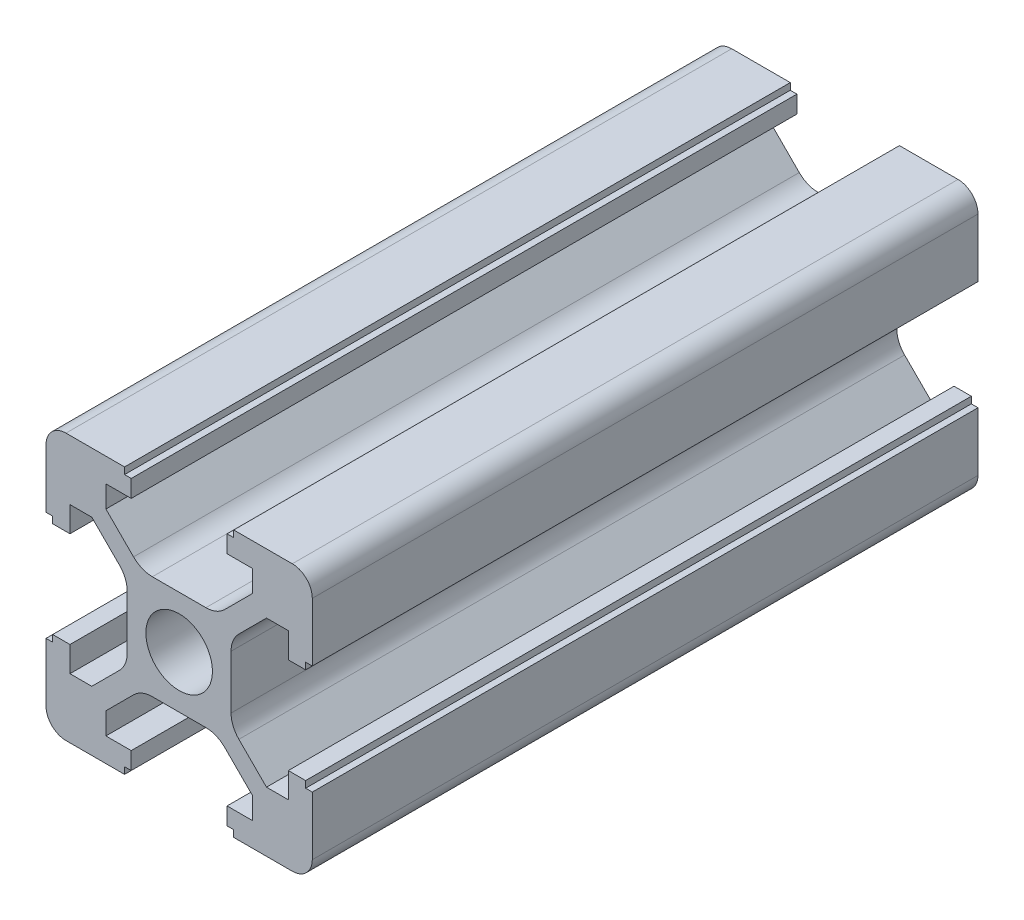
from build123d import *

# Parameters (mm, degrees)
SKETCH1_R           = 2.5
BOSS_EXTRUDE2_DEPTH = 50


with BuildPart() as part:
    # Sketch1 → Boss-Extrude2 (new body)
    with BuildSketch(Plane.XY):
        with BuildLine():
            Line((10, -4.1), (10, -8.5))
            ThreePointArc((10, -8.5), (9.560660172, -9.560660172), (8.5, -10))
            Line((8.5, -10), (4.1, -10))
            Line((4.1, -10), (4.1, -9.5))
            Line((4.1, -9.5), (3.6, -9.5))
            Line((3.6, -9.5), (3.6, -8.2))
            Line((3.6, -8.2), (5.5, -8.2))
            Line((5.5, -8.2), (5.5, -6.560660172))
            Line((5.5, -6.560660172), (3.425126266, -4.485786438))
            ThreePointArc((3.425126266, -4.485786438), (2.776279568, -4.052240935), (2.010912703, -3.9))
            Line((2.010912703, -3.9), (-2.010912703, -3.9))
            ThreePointArc((-2.010912703, -3.9), (-2.776279568, -4.052240935), (-3.425126266, -4.485786438))
            Line((-3.425126266, -4.485786438), (-5.5, -6.560660172))
            Line((-5.5, -6.560660172), (-5.5, -8.2))
            Line((-5.5, -8.2), (-3.6, -8.2))
            Line((-3.6, -8.2), (-3.6, -9.5))
            Line((-3.6, -9.5), (-4.1, -9.5))
            Line((-4.1, -9.5), (-4.1, -10))
            Line((-4.1, -10), (-8.5, -10))
            ThreePointArc((-8.5, -10), (-9.560660172, -9.560660172), (-10, -8.5))
            Line((-10, -8.5), (-10, -4.1))
            Line((-10, -4.1), (-9.5, -4.1))
            Line((-9.5, -4.1), (-9.5, -3.6))
            Line((-9.5, -3.6), (-8.2, -3.6))
            Line((-8.2, -3.6), (-8.2, -5.5))
            Line((-8.2, -5.5), (-6.560660172, -5.5))
            Line((-6.560660172, -5.5), (-4.485786438, -3.425126266))
            ThreePointArc((-4.485786438, -3.425126266), (-4.052240935, -2.776279568), (-3.9, -2.010912703))
            Line((-3.9, -2.010912703), (-3.9, 2.010912703))
            ThreePointArc((-3.9, 2.010912703), (-4.052240935, 2.776279568), (-4.485786438, 3.425126266))
            Line((-4.485786438, 3.425126266), (-6.560660172, 5.5))
            Line((-6.560660172, 5.5), (-8.2, 5.5))
            Line((-8.2, 5.5), (-8.2, 3.6))
            Line((-8.2, 3.6), (-9.5, 3.6))
            Line((-9.5, 3.6), (-9.5, 4.1))
            Line((-9.5, 4.1), (-10, 4.1))
            Line((-10, 4.1), (-10, 8.5))
            ThreePointArc((-10, 8.5), (-9.560660172, 9.560660172), (-8.5, 10))
            Line((-8.5, 10), (-4.1, 10))
            Line((-4.1, 10), (-4.1, 9.5))
            Line((-4.1, 9.5), (-3.6, 9.5))
            Line((-3.6, 9.5), (-3.6, 8.2))
            Line((-3.6, 8.2), (-5.5, 8.2))
            Line((-5.5, 8.2), (-5.5, 6.560660172))
            Line((-5.5, 6.560660172), (-3.425126266, 4.485786438))
            ThreePointArc((-3.425126266, 4.485786438), (-2.776279568, 4.052240935), (-2.010912703, 3.9))
            Line((-2.010912703, 3.9), (2.010912703, 3.9))
            ThreePointArc((2.010912703, 3.9), (2.776279568, 4.052240935), (3.425126266, 4.485786438))
            Line((3.425126266, 4.485786438), (5.5, 6.560660172))
            Line((5.5, 6.560660172), (5.5, 8.2))
            Line((5.5, 8.2), (3.6, 8.2))
            Line((3.6, 8.2), (3.6, 9.5))
            Line((3.6, 9.5), (4.1, 9.5))
            Line((4.1, 9.5), (4.1, 10))
            Line((4.1, 10), (8.5, 10))
            ThreePointArc((8.5, 10), (9.560660172, 9.560660172), (10, 8.5))
            Line((10, 8.5), (10, 4.1))
            Line((10, 4.1), (9.5, 4.1))
            Line((9.5, 4.1), (9.5, 3.6))
            Line((9.5, 3.6), (8.2, 3.6))
            Line((8.2, 3.6), (8.2, 5.5))
            Line((8.2, 5.5), (6.560660172, 5.5))
            Line((6.560660172, 5.5), (4.485786438, 3.425126266))
            ThreePointArc((4.485786438, 3.425126266), (4.052240935, 2.776279568), (3.9, 2.010912703))
            Line((3.9, 2.010912703), (3.9, -2.010912703))
            ThreePointArc((3.9, -2.010912703), (4.052240935, -2.776279568), (4.485786438, -3.425126266))
            Line((4.485786438, -3.425126266), (6.560660172, -5.5))
            Line((6.560660172, -5.5), (8.2, -5.5))
            Line((8.2, -5.5), (8.2, -3.6))
            Line((8.2, -3.6), (9.5, -3.6))
            Line((9.5, -3.6), (9.5, -4.1))
            Line((9.5, -4.1), (10, -4.1))
        make_face()
        Circle(SKETCH1_R, mode=Mode.SUBTRACT)
    extrude(amount=BOSS_EXTRUDE2_DEPTH)


solid = part.part
